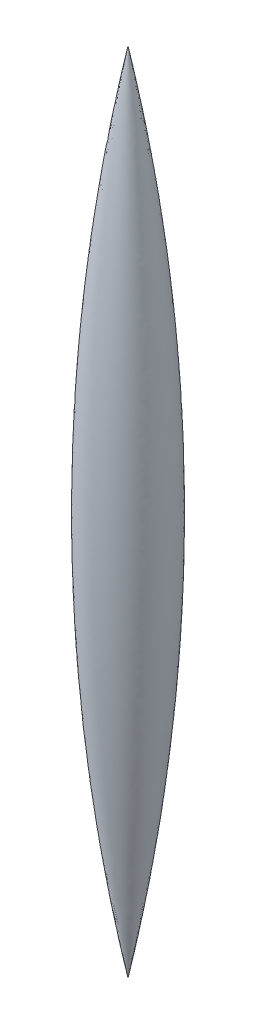
from build123d import *


with BuildPart() as part:
    # Sketch5 → Revolve1 (revolve)
    with BuildSketch(Plane.XY):
        with BuildLine():
            Line((0, 63.5), (0, -63.5))
            ThreePointArc((0, -63.5), (6.284117306, 0), (0, 63.5))
        make_face()
    revolve(axis=Axis((0, 63.5, 0), (0, -1, 0)))


solid = part.part
